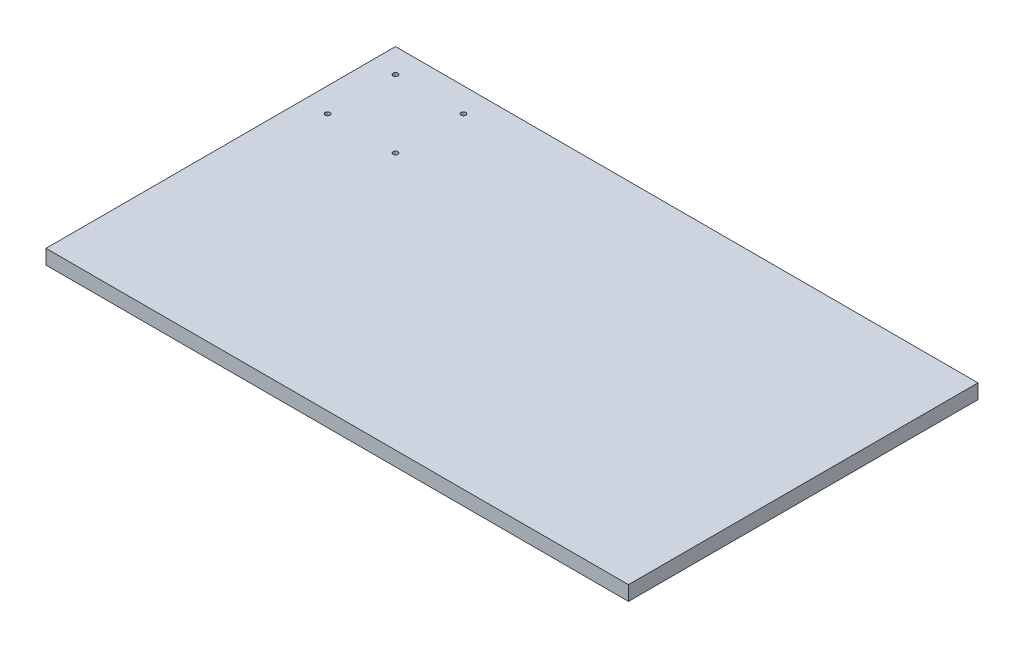
from build123d import *

# Parameters (mm, degrees)
SKETCH1_W            = 3048
SKETCH1_H            = 1828.8
BOSS_EXTRUDE1_DEPTH  = 76.2
SKETCH2_W            = 2895.6
SKETCH2_H            = 1676.4
CUT_EXTRUDE1_DEPTH   = 50.8
SKETCH3_R            = 12.7
CUT_EXTRUDE2_DEPTH   = 77.2
LPATTERN1_COUNT      = 2
LPATTERN1_PITCH      = 355.6
LPATTERN1_COUNT_DIR2 = 2
LPATTERN1_PITCH_DIR2 = 355.6


with BuildPart() as part:
    # Sketch1 → Boss-Extrude1 (new body)
    with BuildSketch(Plane(origin=(0, 0, 0), x_dir=(1, 0, 0), z_dir=(0, 1, 0))):
        with Locations((1524, 914.4)):
            Rectangle(SKETCH1_W, SKETCH1_H)
    extrude(amount=BOSS_EXTRUDE1_DEPTH)

    # Sketch2 → Cut-Extrude1 (cut)
    with BuildSketch(Plane.XZ):
        with Locations((1524, -914.4)):
            Rectangle(SKETCH2_W, SKETCH2_H)
    extrude(amount=-CUT_EXTRUDE1_DEPTH, mode=Mode.SUBTRACT)

    # Sketch3 → Cut-Extrude2 (cut, through all)
    with BuildSketch(Plane(origin=(0, 76.2, 0), x_dir=(1, 0, 0), z_dir=(0, 1, 0))):
        with Locations((127, 1701.8)):
            Circle(SKETCH3_R)
    cut_extrude2 = extrude(amount=-CUT_EXTRUDE2_DEPTH, mode=Mode.SUBTRACT)

    # LPattern1: Cut-Extrude2 2 × 2
    with Locations(*[(i * LPATTERN1_PITCH, 0, j * LPATTERN1_PITCH_DIR2) for i in range(LPATTERN1_COUNT) for j in range(LPATTERN1_COUNT_DIR2) if (i, j) != (0, 0)]):
        add(cut_extrude2, mode=Mode.SUBTRACT)


solid = part.part
